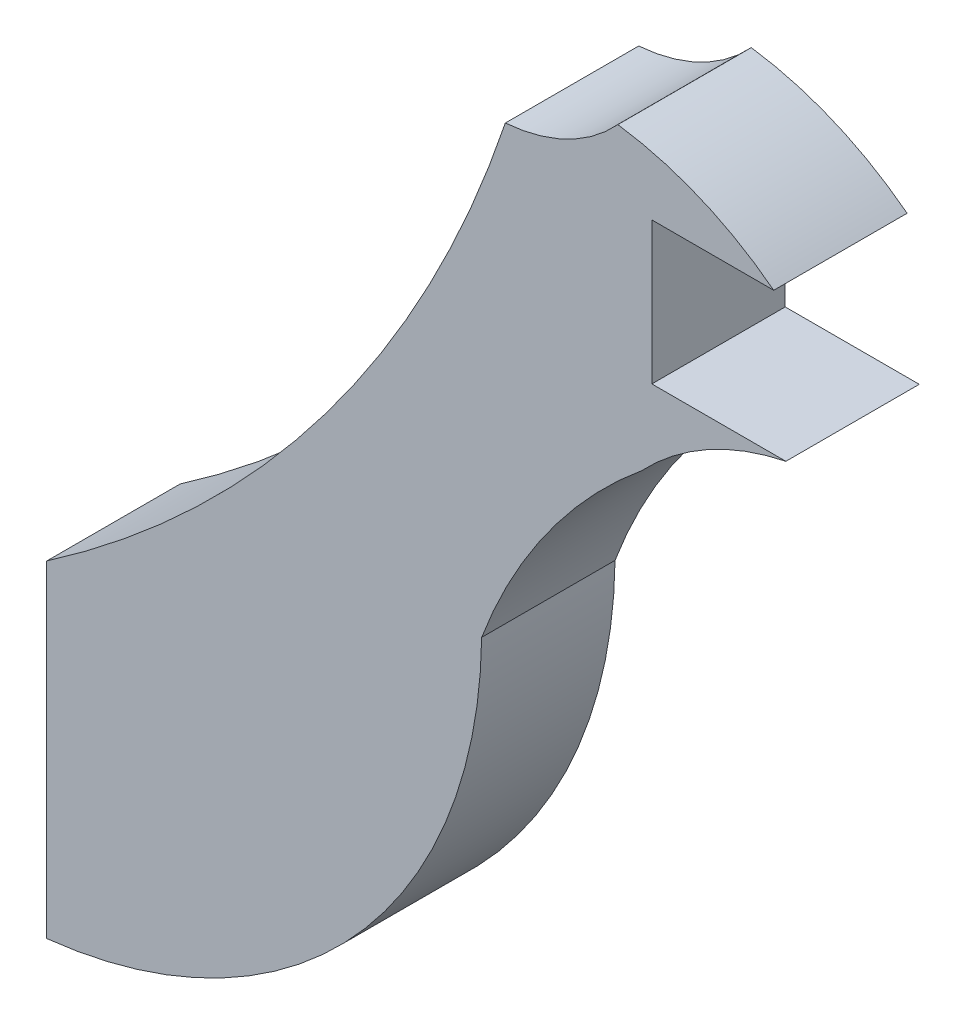
from build123d import *

# Parameters (mm, degrees)
BOSS_EXTRUDE1_DEPTH = 1.524


with BuildPart() as part:
    # Sketch1 → Boss-Extrude1 (new body)
    with BuildSketch(Plane.XY):
        with BuildLine():
            Line((110.824360774, -1.524), (109.29292347, -1.524))
            Line((109.29292347, -1.524), (109.29292347, 0.099254425))
            Line((109.29292347, 0.099254425), (110.685720546, 0.099254425))
            ThreePointArc((110.685720546, 0.099254425), (109.844126395, 0.589914025), (108.904790048, 0.848128638))
            ThreePointArc((108.904790048, 0.848128638), (108.321557599, 0.411980775), (107.618800979, 0.220883469))
            ThreePointArc((107.618800979, 0.220883469), (105.564728066, -3.682348009), (102.379001913, -6.732852948))
            Line((102.379001913, -6.732852948), (102.379001913, -10.469177864))
            ThreePointArc((102.379001913, -10.469177864), (105.901664911, -8.680555585), (107.348345234, -5.004220414))
            ThreePointArc((107.348345234, -5.004220414), (108.094332128, -3.601037602), (109.178159994, -2.438826088))
            ThreePointArc((109.178159994, -2.438826088), (109.930755444, -1.854541621), (110.824360774, -1.524))
        make_face()
    extrude(amount=BOSS_EXTRUDE1_DEPTH)


solid = part.part
